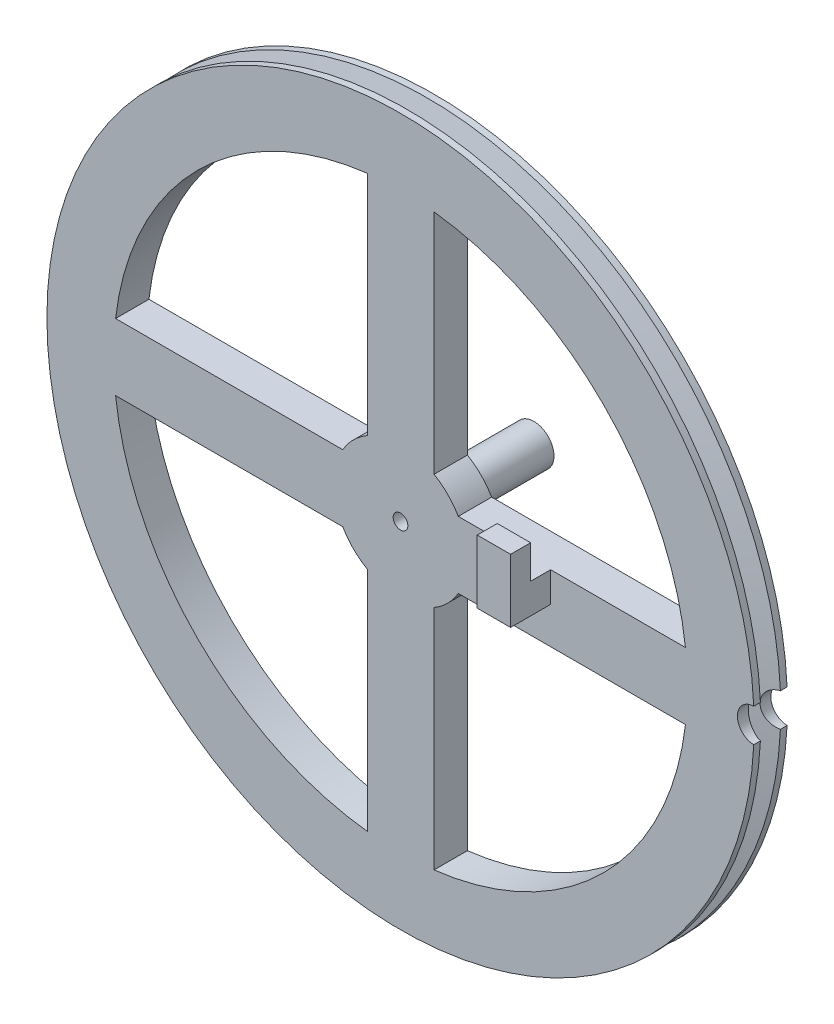
from build123d import *

# Parameters (mm, degrees)
CUT_EXTRUDE2_REACH      = 77.12
SKETCH6_W               = 5
SKETCH6_H               = 4.5
BOSS_EXTRUDE1_DEPTH     = 6
SKETCH7_W               = 5
SKETCH7_H               = 3
BOSS_EXTRUDE2_DEPTH     = 5
SKETCH23_R              = 3
BOSS_EXTRUDE5_DEPTH     = 15
CUT_EXTRUDE3_DEPTH      = 78.575769413
CUT_EXTRUDE3_DEPTH_BACK = 78.575769413
SKETCH5_R               = 1.1
CUT_EXTRUDE4_DEPTH      = 77.969149664
CUT_EXTRUDE4_DEPTH_BACK = 77.969149664
SKETCH22_R              = 2.5
SKETCH21_R              = 0.25
CUT_EXTRUDE5_DEPTH      = 2.5


with BuildPart() as part:
    # Sketch2 → Revolve1 (revolve)
    with BuildSketch(Plane(origin=(0, 0, 0), x_dir=(1, 0, 0), z_dir=(0, 1, 0))):
        Polygon((53, -1.5), (49, -0.5), (49, 0.5), (53, 1.5), (53, 2.5), (50, 2.5), (0, 2.5), (0, -2.5), (50, -2.5), (53, -2.5), align=None)
    revolve(axis=Axis((0, 0, -2.5), (0, 0, 1)))

    # Sketch4 → Cut-Extrude2 (cut, up to next)
    with BuildSketch(Plane.XY.offset(2.5), mode=Mode.PRIVATE) as cut_extrude2_sk1:
        with BuildLine():
            Line((5.026990014, 8.644615168), (5.026990014, 42.705144554))
            ThreePointArc((5.026990014, 42.705144554), (30.415198012, 30.395982134), (42.708313008, 5))
            Line((42.708313008, 5), (8.660254038, 5))
            ThreePointArc((8.660254038, 5), (7.082087783, 7.06003064), (5.026990014, 8.644615168))
        make_face()
    cut_extrude2_tool1 = extrude(cut_extrude2_sk1.sketch, amount=-CUT_EXTRUDE2_REACH, mode=Mode.PRIVATE) & part.part
    # Sketch4 → Cut-Extrude2 (cut, up to next)
    with BuildSketch(Plane.XY.offset(2.5), mode=Mode.PRIVATE) as cut_extrude2_sk2:
        with BuildLine():
            Line((-4.973009986, -42.711464172), (-4.973009986, -8.675780754))
            ThreePointArc((-4.973009986, -8.675780754), (-7.060050497, -7.082067988), (-8.660254038, -5))
            Line((-8.660254038, -5), (-42.708313008, -5))
            ThreePointArc((-42.708313008, -5), (-30.395982845, -30.415197302), (-4.973009986, -42.711464172))
        make_face()
    cut_extrude2_tool2 = extrude(cut_extrude2_sk2.sketch, amount=-CUT_EXTRUDE2_REACH, mode=Mode.PRIVATE) & part.part
    # Sketch4 → Cut-Extrude2 (cut, up to next)
    with BuildSketch(Plane.XY.offset(2.5), mode=Mode.PRIVATE) as cut_extrude2_sk3:
        with BuildLine():
            Line((5.026990014, -42.705144554), (5.026990014, -8.644615168))
            ThreePointArc((5.026990014, -8.644615168), (7.082087783, -7.06003064), (8.660254038, -5))
            Line((8.660254038, -5), (42.708313008, -5))
            ThreePointArc((42.708313008, -5), (30.415198012, -30.395982134), (5.026990014, -42.705144554))
        make_face()
    cut_extrude2_tool3 = extrude(cut_extrude2_sk3.sketch, amount=-CUT_EXTRUDE2_REACH, mode=Mode.PRIVATE) & part.part
    # Sketch4 → Cut-Extrude2 (cut, up to next)
    with BuildSketch(Plane.XY.offset(2.5), mode=Mode.PRIVATE) as cut_extrude2_sk4:
        with BuildLine():
            Line((-42.708313008, 5), (-8.660254038, 5))
            ThreePointArc((-8.660254038, 5), (-7.060050497, 7.082067988), (-4.973009986, 8.675780754))
            Line((-4.973009986, 8.675780754), (-4.973009986, 42.711464172))
            ThreePointArc((-4.973009986, 42.711464172), (-30.395982845, 30.415197302), (-42.708313008, 5))
        make_face()
    cut_extrude2_tool4 = extrude(cut_extrude2_sk4.sketch, amount=-CUT_EXTRUDE2_REACH, mode=Mode.PRIVATE) & part.part
    add(cut_extrude2_tool1.solids().sort_by_distance((20.56337, 20.545095, 2.5))[0], mode=Mode.SUBTRACT)
    add(cut_extrude2_tool2.solids().sort_by_distance((-20.535898, -20.554166, 2.5))[0], mode=Mode.SUBTRACT)
    add(cut_extrude2_tool3.solids().sort_by_distance((20.56337, -20.545095, 2.5))[0], mode=Mode.SUBTRACT)
    add(cut_extrude2_tool4.solids().sort_by_distance((-20.535898, 20.554166, 2.5))[0], mode=Mode.SUBTRACT)

    # Sketch6 → Boss-Extrude1 (add)
    with BuildSketch(Plane.XY.offset(2.5)):
        with Locations((20, 2.75)):
            Rectangle(SKETCH6_W, SKETCH6_H)
    extrude(amount=BOSS_EXTRUDE1_DEPTH)

    # Sketch7 → Boss-Extrude2 (add)
    with BuildSketch(Plane(origin=(0, 5, 0), x_dir=(1, 0, 0), z_dir=(0, 1, 0))):
        with Locations((20, -7)):
            Rectangle(SKETCH7_W, SKETCH7_H)
    extrude(amount=BOSS_EXTRUDE2_DEPTH)

    # Sketch23 → Boss-Extrude5 (add)
    with BuildSketch(Plane(origin=(0, 0, -2.5), x_dir=(-1, 0, 0), z_dir=(0, 0, -1))):
        Circle(SKETCH23_R)
    extrude(amount=BOSS_EXTRUDE5_DEPTH)

    # Sketch5 → Cut-Extrude3 (cut, two sides: drawn at the far end of the back side and taken through both)
    with BuildSketch(Plane.XY.offset(2.5).offset(-CUT_EXTRUDE3_DEPTH_BACK)):
        Circle(SKETCH5_R)
    extrude(amount=CUT_EXTRUDE3_DEPTH + CUT_EXTRUDE3_DEPTH_BACK, mode=Mode.SUBTRACT)

    # Sketch22 → Cut-Extrude4 (cut, two sides: drawn at the far end of the back side and taken through both)
    with BuildSketch(Plane.XY.offset(-CUT_EXTRUDE4_DEPTH_BACK)):
        with Locations((53, 0)):
            Circle(SKETCH22_R)
    extrude(amount=CUT_EXTRUDE4_DEPTH + CUT_EXTRUDE4_DEPTH_BACK, mode=Mode.SUBTRACT)

    # Sketch21 → Cut-Extrude5 (cut)
    with BuildSketch(Plane(origin=(49, 0, 0), x_dir=(0, 0, -1), z_dir=(1, 0, 0))):
        Circle(SKETCH21_R)
    extrude(amount=-CUT_EXTRUDE5_DEPTH, mode=Mode.SUBTRACT)


solid = part.part
